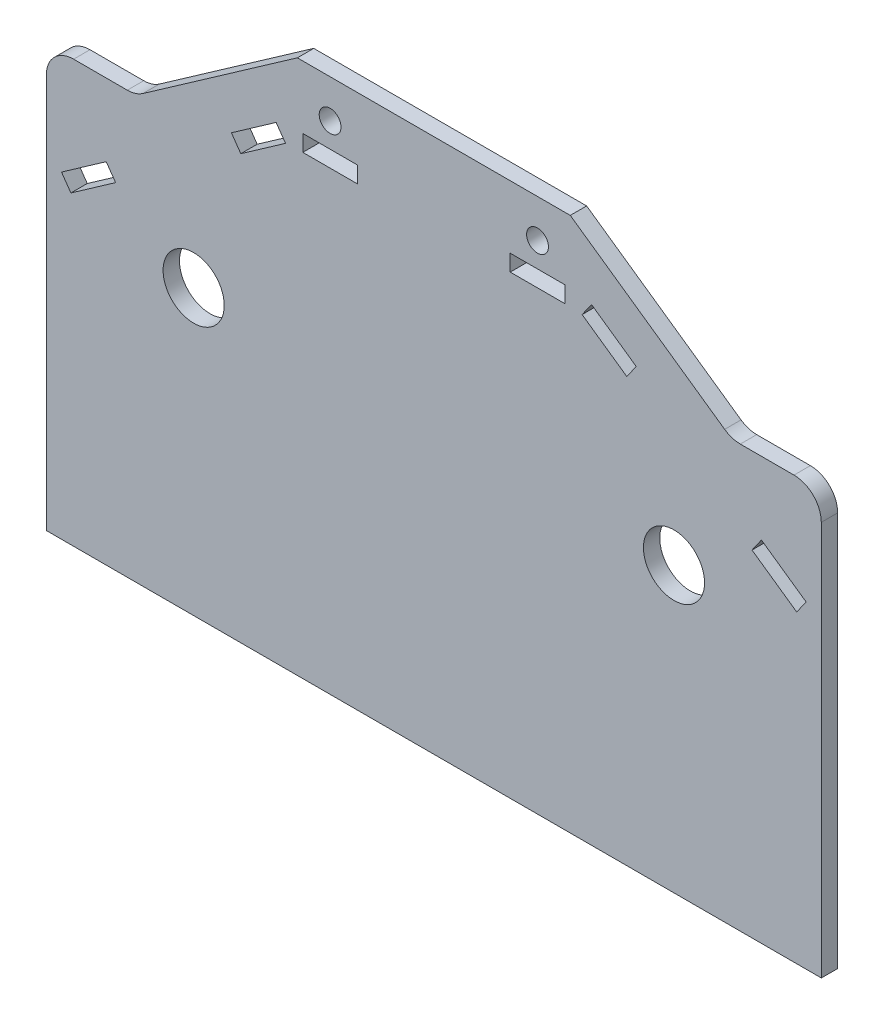
from build123d import *

# Parameters (mm, degrees)
MODEL_R                 = 5.602685567
MODEL_R_2               = 2
MODEL_W                 = 10
MODEL_H                 = 3
SALIENTE_EXTRUIR1_DEPTH = 3


with BuildPart() as part:
    # Model → Saliente-Extruir1 (new body)
    with BuildSketch(Plane.XY):
        with BuildLine():
            Line((40.656841206, 68.2), (-1.7, 68.2))
            Line((-1.7, 68.2), (-29.984726632, 48.394821196))
            ThreePointArc((-29.984726632, 48.394821196), (-31.349079816, 47.721996664), (-32.852608814, 47.490581417))
            Line((-32.852608814, 47.490581417), (-42.689839841, 47.490581417))
            ThreePointArc((-42.689839841, 47.490581417), (-46.225125286, 46.026363766), (-47.689839791, 42.491284145))
            Line((-47.689839791, 42.491284145), (-47.7, -29.8))
            Line((-47.7, -29.8), (-18.946904924, -29.8))
            Line((-18.946904924, -29.8), (62.3, -29.8))
            Line((62.3, -29.8), (69.836645163, -29.8))
            Line((69.836645163, -29.8), (73.3, -29.8))
            Line((73.3, -29.8), (94.3, -29.8))
            Line((94.3, -29.8), (94.289839791, 42.491284145))
            ThreePointArc((94.289839791, 42.491284145), (92.825125286, 46.026363766), (89.289839841, 47.490581417))
            Line((89.289839841, 47.490581417), (79.452608814, 47.490581417))
            ThreePointArc((79.452608814, 47.490581417), (77.949079816, 47.721996664), (76.584726632, 48.394821196))
            Line((76.584726632, 48.394821196), (48.3, 68.2))
            Line((48.3, 68.2), (40.656841206, 68.2))
        make_face()
        with Locations((-20.7, 22.2)):
            Circle(MODEL_R, mode=Mode.SUBTRACT)
        with Locations((67.3, 22.2)):
            Circle(MODEL_R, mode=Mode.SUBTRACT)
        with Locations((42.3, 61.2)):
            Circle(MODEL_R_2, mode=Mode.SUBTRACT)
        with Locations((4.3, 61.2)):
            Circle(MODEL_R_2, mode=Mode.SUBTRACT)
        with Locations((4.3, 55.2)):
            Rectangle(MODEL_W, MODEL_H, mode=Mode.SUBTRACT)
        Polygon((58.660844318, 47.809630387), (60.381573627, 50.26708652), (52.190053184, 56.002850883), (50.469323875, 53.545394751), align=None, mode=Mode.SUBTRACT)
        with Locations((42.3, 55.2)):
            Rectangle(MODEL_W, MODEL_H, mode=Mode.SUBTRACT)
        Polygon((-12.060844318, 47.809630387), (-13.781573627, 50.26708652), (-5.590053184, 56.002850883), (-3.869323875, 53.545394751), align=None, mode=Mode.SUBTRACT)
        Polygon((-34.997101558, 31.749490169), (-36.717830867, 34.206946302), (-44.90935131, 28.471181939), (-43.188622001, 26.013725806), align=None, mode=Mode.SUBTRACT)
        Polygon((81.597101558, 31.749490169), (83.317830867, 34.206946302), (91.50935131, 28.471181939), (89.788622001, 26.013725806), align=None, mode=Mode.SUBTRACT)
    extrude(amount=SALIENTE_EXTRUIR1_DEPTH)


solid = part.part
